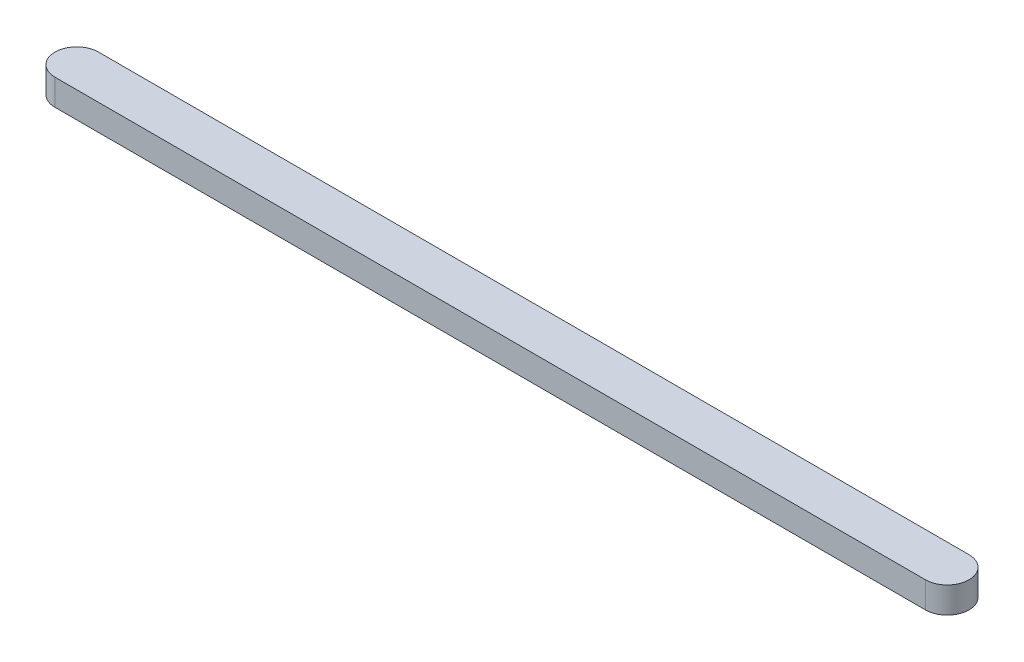
from build123d import *

# Parameters (mm, degrees)
BOSS_EXTRUDE1_DEPTH = 6


with BuildPart() as part:
    # Sketch1 → Boss-Extrude1 (new body)
    with BuildSketch(Plane(origin=(0, 0, 0), x_dir=(1, 0, 0), z_dir=(0, 1, 0))):
        with BuildLine():
            Line((0, 5), (200, 5))
            ThreePointArc((200, 5), (205, 0), (200, -5))
            Line((200, -5), (0, -5))
            ThreePointArc((0, -5), (-5, 0), (0, 5))
        make_face()
    extrude(amount=BOSS_EXTRUDE1_DEPTH)


solid = part.part
